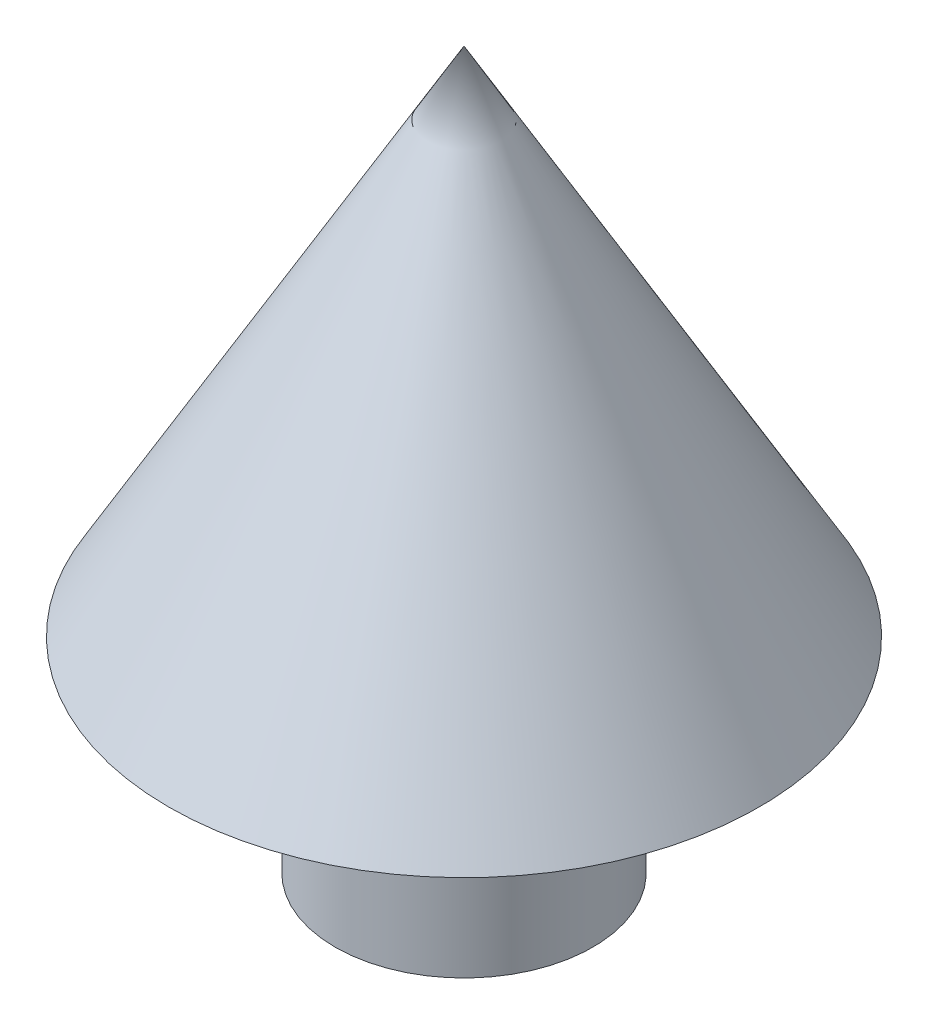
from build123d import *


with BuildPart() as part:
    # Sketch2 → Revolve1 (revolve)
    with BuildSketch(Plane(origin=(0, 0, 0), x_dir=(0, 0, -1), z_dir=(1, 0, 0))):
        Polygon((0, 0), (0, 35), (-14.43375673, 10), (-6.3, 10), (-6.3, 0), align=None)
    revolve(axis=Axis((0, 0, 0), (0, 1, 0)))


solid = part.part
